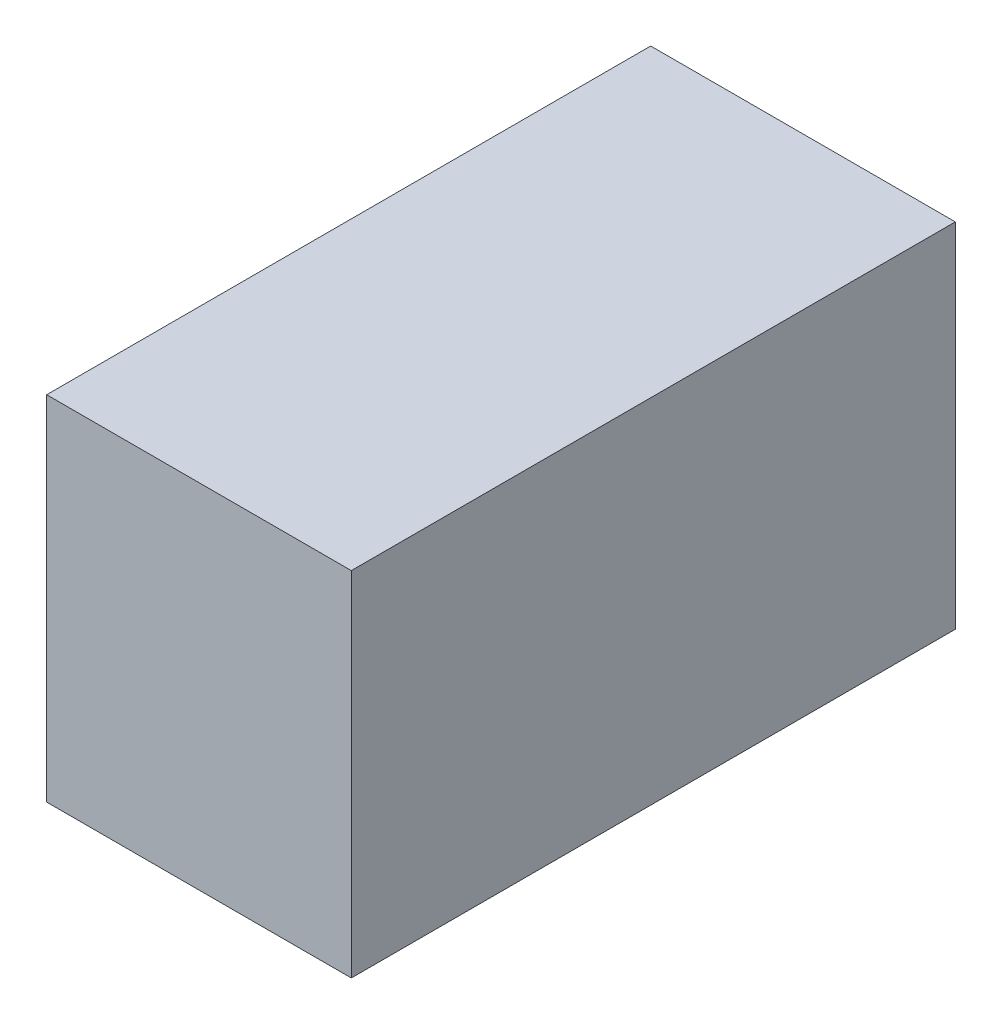
from build123d import *

# Parameters (mm, degrees)
SKETCH1_W           = 23.2
SKETCH1_H           = 26.87
BOSS_EXTRUDE2_DEPTH = 46


with BuildPart() as part:
    # Sketch1 → Boss-Extrude2 (new body)
    with BuildSketch(Plane.XY):
        with Locations((-3.007896825, 0.746388889)):
            Rectangle(SKETCH1_W, SKETCH1_H)
    extrude(amount=BOSS_EXTRUDE2_DEPTH)


solid = part.part
